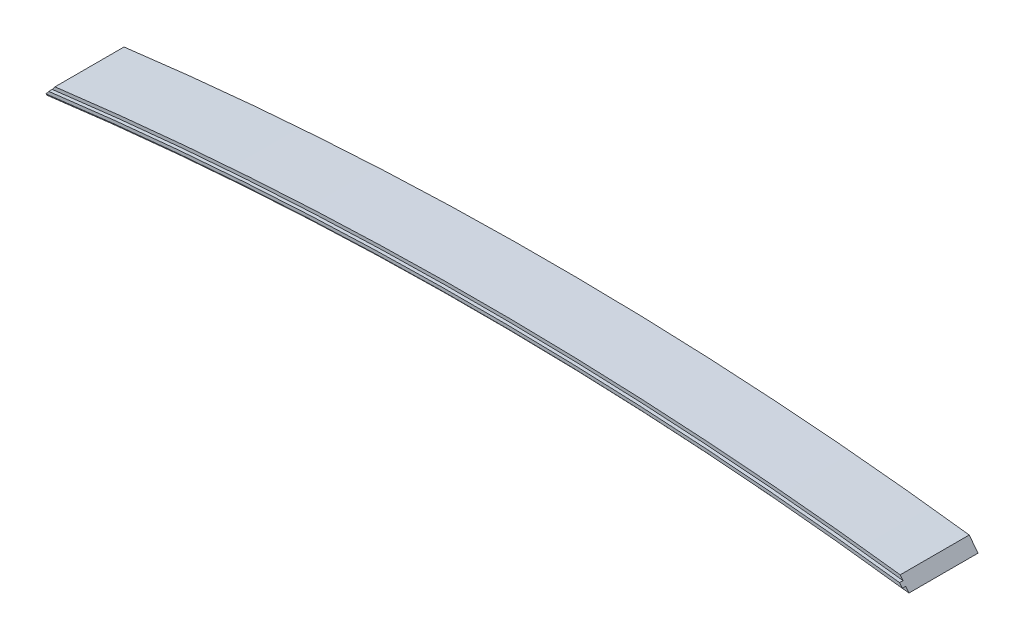
from build123d import *

# Parameters (mm, degrees)
BOSS_EXTRUDE1_DEPTH = 101.6
BOSS_EXTRUDE2_DEPTH = 5.08


with BuildPart() as part:
    # Sketch1 → Boss-Extrude1 (new body)
    with BuildSketch(Plane.XY):
        with BuildLine():
            Line((-635, -99.977394786), (-622.103936151, -83.199836272))
            ThreePointArc((-622.103936151, -83.199836272), (0, -43.636564626), (622.103936151, -83.199836272))
            Line((622.103936151, -83.199836272), (635, -99.977394786))
            ThreePointArc((635, -99.977394786), (0, -58.622564626), (-635, -99.977394786))
        make_face()
    extrude(amount=BOSS_EXTRUDE1_DEPTH)

    # Sketch2 → Boss-Extrude2 (add)
    with BuildSketch(Plane.XY.offset(101.6)):
        with BuildLine():
            Line((-626.208942531, -88.540379367), (-630.25231332, -93.800735613))
            ThreePointArc((-630.25231332, -93.800735613), (0, -53.110764626), (630.25231332, -93.800735613))
            Line((630.25231332, -93.800735613), (626.208942531, -88.540379367))
            ThreePointArc((626.208942531, -88.540379367), (0, -48.411764626), (-626.208942531, -88.540379367))
        make_face()
    extrude(amount=BOSS_EXTRUDE2_DEPTH)


solid = part.part
